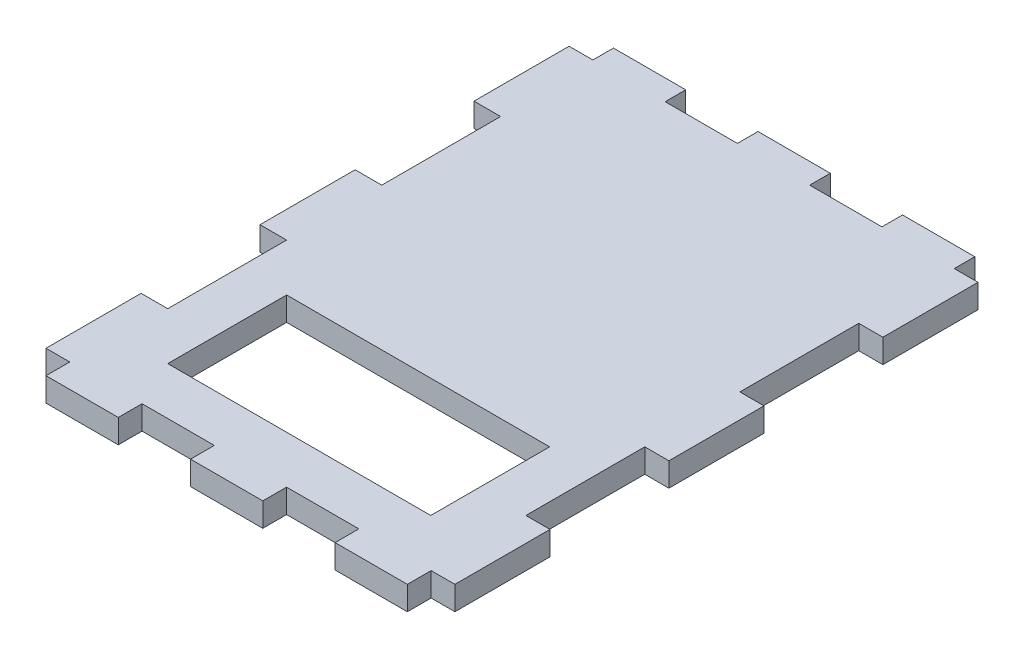
from build123d import *

# Parameters (mm, degrees)
BOSS_EXTRUDE1_DEPTH = 5.08
SKETCH5_W           = 56.19760994
SKETCH5_H           = 25.4
CUT_EXTRUDE1_DEPTH  = 50.8


with BuildPart() as part:
    # Sketch1 → Boss-Extrude1 (new body)
    with BuildSketch(Plane(origin=(0, 0, 0), x_dir=(1, 0, 0), z_dir=(0, 1, 0))):
        Polygon((-101.738774191, -22.048282475), (-101.738774191, -27.128282475), (-86.298774591, -27.128282475), (-86.298774591, -22.048282475), (-70.858774991, -22.048282475), (-70.858774991, -27.128282475), (-55.418775391, -27.128282475), (-55.418775391, -22.048282475), (-39.978775791, -22.048282475), (-39.978775791, -27.128282475), (-24.538776191, -27.128282475), (-24.538776191, -22.048282475), (-19.458776191, -22.048282475), (-19.458776191, -1.728282475), (-24.614597086, -1.728282475), (-24.614597086, 23.671717525), (-19.458776191, 23.671717525), (-19.458776191, 43.991717525), (-24.614597086, 43.991717525), (-24.614597086, 69.391717525), (-19.458776191, 69.391717525), (-19.458776191, 89.711717525), (-24.538776191, 89.711717525), (-24.538776191, 94.109329465), (-39.978775791, 94.109329465), (-39.978775791, 89.711717525), (-55.418775391, 89.711717525), (-55.418775391, 94.109329465), (-70.858774991, 94.109329465), (-70.858774991, 89.711717525), (-86.298774591, 89.711717525), (-86.298774591, 94.109329465), (-101.738774191, 94.109329465), (-101.738774191, 89.711717525), (-106.818774191, 89.711717525), (-106.818774191, 69.391717525), (-101.132207026, 69.391717525), (-101.132207026, 43.991717525), (-106.818774191, 43.991717525), (-106.818774191, 23.671717525), (-101.132207026, 23.671717525), (-101.132207026, -1.728282475), (-106.818774191, -1.728282475), (-106.818774191, -22.048282475), align=None)
    extrude(amount=BOSS_EXTRUDE1_DEPTH)

    # Sketch5 → Cut-Extrude1 (cut)
    with BuildSketch(Plane(origin=(0, 5.08, 0), x_dir=(1, 0, 0), z_dir=(0, 1, 0))):
        with Locations((-62.873402056, 0.811717525)):
            Rectangle(SKETCH5_W, SKETCH5_H)
    extrude(amount=-CUT_EXTRUDE1_DEPTH, mode=Mode.SUBTRACT)


solid = part.part
